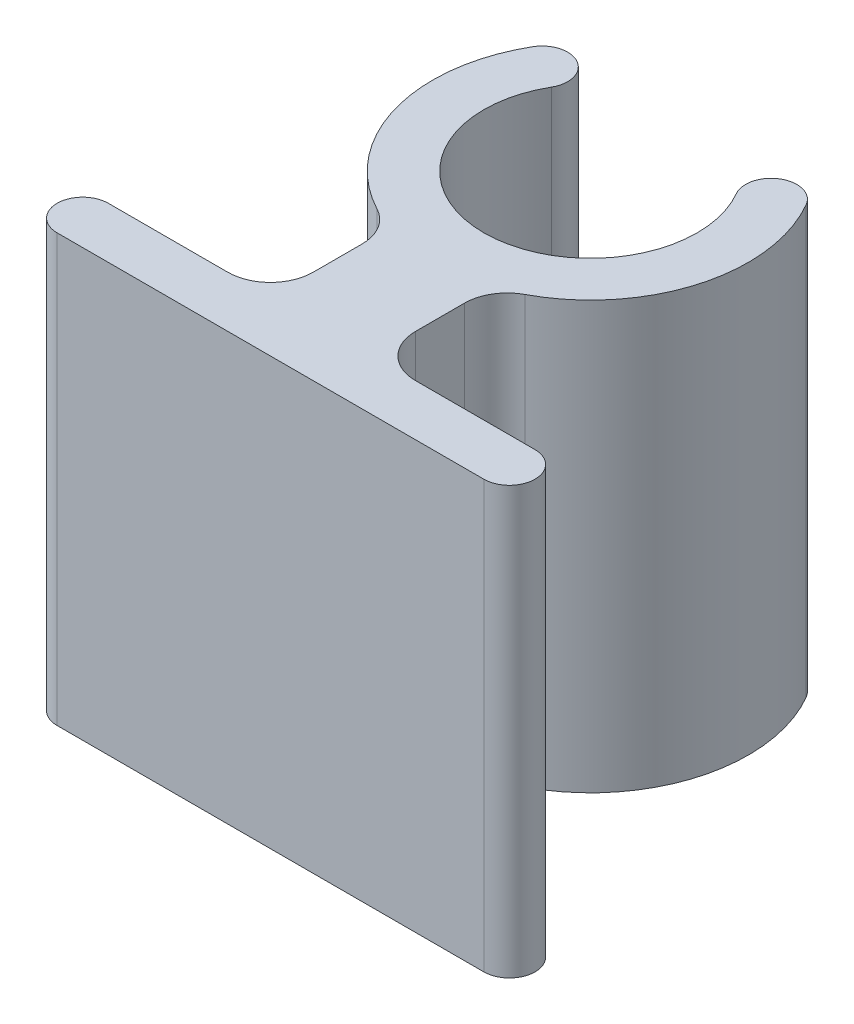
from build123d import *

# Parameters (mm, degrees)
BOSS_EXTRUDE1_DEPTH = 10
FILLET1_R           = 1


with BuildPart() as part:
    # Sketch1 → Boss-Extrude1 (new body)
    with BuildSketch(Plane(origin=(0, 0, 0), x_dir=(1, 0, 0), z_dir=(0, 1, 0))):
        with BuildLine():
            Line((0, -2.5), (0, -7.5))
            Line((0, -7.5), (-5, -7.5))
            ThreePointArc((-5, -7.5), (-5.6, -6.9), (-5, -6.3))
            Line((-5, -6.3), (-1.2, -6.3))
            Line((-1.2, -6.3), (-1.2, -3.5))
            ThreePointArc((-1.2, -3.5), (-3.464834252, -1.298046071), (-3.204293994, 1.85))
            ThreePointArc((-3.204293994, 1.85), (-2.384678752, 2.069615242), (-2.165063509, 1.25))
            ThreePointArc((-2.165063509, 1.25), (-2.165063509, -1.25), (0, -2.5))
        make_face()
    extrude(amount=BOSS_EXTRUDE1_DEPTH)

    # Fillet1
    fillet1_edges = [part.edges().sort_by_distance(p)[0] for p in [
        (-1.2, 5, 6.3),
        (-1.2, 5, 3.5),
    ]]
    fillet(fillet1_edges, radius=FILLET1_R)

    # Mirror1: part across plane


with BuildPart() as part_1:
    add(part.part)
    add(part.part.mirror(Plane(origin=(0, 10, 2.5), x_dir=(0, 0, 1), z_dir=(-1, 0, 0))))


solid = part_1.part
